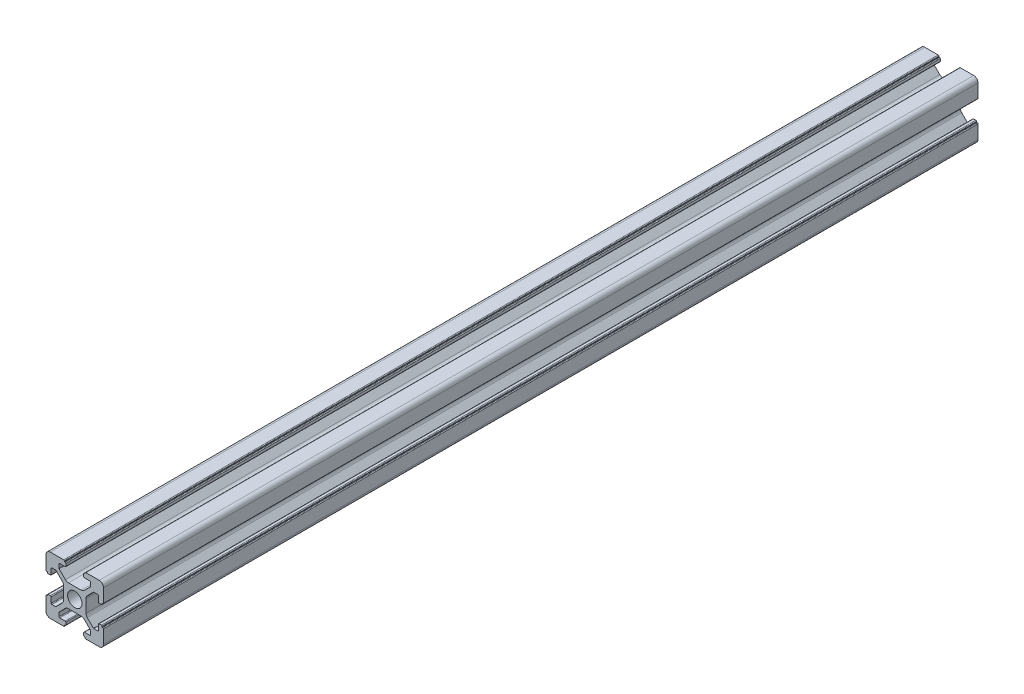
from build123d import *

# Parameters (mm, degrees)
SKETCH_1_R      = 2.5
EXTRUDE_1_DEPTH = 304


with BuildPart() as part:
    # 草图1 → 凸台-拉伸1 (new body)
    with BuildSketch(Plane.XY):
        with BuildLine():
            Line((-8.502261885, -10.002261885), (-3.85, -10.002261885))
            ThreePointArc((-3.85, -10.002261885), (-3.673223305, -9.929038581), (-3.6, -9.752261885))
            Line((-3.6, -9.752261885), (-3.6, -9.502261885))
            Line((-3.6, -9.502261885), (-3.35, -9.502261885))
            ThreePointArc((-3.35, -9.502261885), (-3.173223305, -9.429038581), (-3.1, -9.252261885))
            Line((-3.1, -9.252261885), (-3.1, -8.45))
            ThreePointArc((-3.1, -8.45), (-3.173223305, -8.273223305), (-3.35, -8.2))
            Line((-3.35, -8.2), (-5.25, -8.2))
            ThreePointArc((-5.25, -8.2), (-5.426776695, -8.126776695), (-5.5, -7.95))
            Line((-5.5, -7.95), (-5.5, -6.664213562))
            ThreePointArc((-5.5, -6.664213562), (-5.480969883, -6.568542704), (-5.426776695, -6.487436867))
            Line((-5.426776695, -6.487436867), (-3.278679656, -4.339339828))
            ThreePointArc((-3.278679656, -4.339339828), (-2.792044633, -4.014180701), (-2.218019485, -3.9))
            Line((-2.218019485, -3.9), (2.218019485, -3.9))
            ThreePointArc((2.218019485, -3.9), (2.792044633, -4.014180701), (3.278679656, -4.339339828))
            Line((3.278679656, -4.339339828), (5.426776695, -6.487436867))
            ThreePointArc((5.426776695, -6.487436867), (5.480969883, -6.568542704), (5.5, -6.664213562))
            Line((5.5, -6.664213562), (5.5, -7.95))
            ThreePointArc((5.5, -7.95), (5.426776695, -8.126776695), (5.25, -8.2))
            Line((5.25, -8.2), (3.35, -8.2))
            ThreePointArc((3.35, -8.2), (3.173223305, -8.273223305), (3.1, -8.45))
            Line((3.1, -8.45), (3.1, -9.252261885))
            ThreePointArc((3.1, -9.252261885), (3.173223305, -9.429038581), (3.35, -9.502261885))
            Line((3.35, -9.502261885), (3.6, -9.502261885))
            Line((3.6, -9.502261885), (3.6, -9.752261885))
            ThreePointArc((3.6, -9.752261885), (3.673223305, -9.929038581), (3.85, -10.002261885))
            Line((3.85, -10.002261885), (8.502261885, -10.002261885))
            ThreePointArc((8.502261885, -10.002261885), (9.562922057, -9.562922057), (10.002261885, -8.502261885))
            Line((10.002261885, -8.502261885), (10.002261885, -3.85))
            ThreePointArc((10.002261885, -3.85), (9.929038581, -3.673223305), (9.752261885, -3.6))
            Line((9.752261885, -3.6), (9.502261885, -3.6))
            Line((9.502261885, -3.6), (9.502261885, -3.35))
            ThreePointArc((9.502261885, -3.35), (9.429038581, -3.173223305), (9.252261885, -3.1))
            Line((9.252261885, -3.1), (8.45, -3.1))
            ThreePointArc((8.45, -3.1), (8.273223305, -3.173223305), (8.2, -3.35))
            Line((8.2, -3.35), (8.2, -5.25))
            ThreePointArc((8.2, -5.25), (8.126776695, -5.426776695), (7.95, -5.5))
            Line((7.95, -5.5), (6.664213562, -5.5))
            ThreePointArc((6.664213562, -5.5), (6.568542704, -5.480969883), (6.487436867, -5.426776695))
            Line((6.487436867, -5.426776695), (4.339339828, -3.278679656))
            ThreePointArc((4.339339828, -3.278679656), (4.014180701, -2.792044633), (3.9, -2.218019485))
            Line((3.9, -2.218019485), (3.9, 2.218019485))
            ThreePointArc((3.9, 2.218019485), (4.014180701, 2.792044633), (4.339339828, 3.278679656))
            Line((4.339339828, 3.278679656), (6.487436867, 5.426776695))
            ThreePointArc((6.487436867, 5.426776695), (6.568542704, 5.480969883), (6.664213562, 5.5))
            Line((6.664213562, 5.5), (7.95, 5.5))
            ThreePointArc((7.95, 5.5), (8.126776695, 5.426776695), (8.2, 5.25))
            Line((8.2, 5.25), (8.2, 3.35))
            ThreePointArc((8.2, 3.35), (8.273223305, 3.173223305), (8.45, 3.1))
            Line((8.45, 3.1), (9.252261885, 3.1))
            ThreePointArc((9.252261885, 3.1), (9.429038581, 3.173223305), (9.502261885, 3.35))
            Line((9.502261885, 3.35), (9.502261885, 3.6))
            Line((9.502261885, 3.6), (9.752261885, 3.6))
            ThreePointArc((9.752261885, 3.6), (9.929038581, 3.673223305), (10.002261885, 3.85))
            Line((10.002261885, 3.85), (10.002261885, 8.502261885))
            ThreePointArc((10.002261885, 8.502261885), (9.562922057, 9.562922057), (8.502261885, 10.002261885))
            Line((8.502261885, 10.002261885), (3.85, 10.002261885))
            ThreePointArc((3.85, 10.002261885), (3.673223305, 9.929038581), (3.6, 9.752261885))
            Line((3.6, 9.752261885), (3.6, 9.502261885))
            Line((3.6, 9.502261885), (3.35, 9.502261885))
            ThreePointArc((3.35, 9.502261885), (3.173223305, 9.429038581), (3.1, 9.252261885))
            Line((3.1, 9.252261885), (3.1, 8.45))
            ThreePointArc((3.1, 8.45), (3.173223305, 8.273223305), (3.35, 8.2))
            Line((3.35, 8.2), (5.25, 8.2))
            ThreePointArc((5.25, 8.2), (5.426776695, 8.126776695), (5.5, 7.95))
            Line((5.5, 7.95), (5.5, 6.664213562))
            ThreePointArc((5.5, 6.664213562), (5.480969883, 6.568542704), (5.426776695, 6.487436867))
            Line((5.426776695, 6.487436867), (3.278679656, 4.339339828))
            ThreePointArc((3.278679656, 4.339339828), (2.792044633, 4.014180701), (2.218019485, 3.9))
            Line((2.218019485, 3.9), (-2.218019485, 3.9))
            ThreePointArc((-2.218019485, 3.9), (-2.792044633, 4.014180701), (-3.278679656, 4.339339828))
            Line((-3.278679656, 4.339339828), (-5.426776695, 6.487436867))
            ThreePointArc((-5.426776695, 6.487436867), (-5.480969883, 6.568542704), (-5.5, 6.664213562))
            Line((-5.5, 6.664213562), (-5.5, 7.95))
            ThreePointArc((-5.5, 7.95), (-5.426776695, 8.126776695), (-5.25, 8.2))
            Line((-5.25, 8.2), (-3.35, 8.2))
            ThreePointArc((-3.35, 8.2), (-3.173223305, 8.273223305), (-3.1, 8.45))
            Line((-3.1, 8.45), (-3.1, 9.252261885))
            ThreePointArc((-3.1, 9.252261885), (-3.173223305, 9.429038581), (-3.35, 9.502261885))
            Line((-3.35, 9.502261885), (-3.6, 9.502261885))
            Line((-3.6, 9.502261885), (-3.6, 9.752261885))
            ThreePointArc((-3.6, 9.752261885), (-3.673223305, 9.929038581), (-3.85, 10.002261885))
            Line((-3.85, 10.002261885), (-8.502261885, 10.002261885))
            ThreePointArc((-8.502261885, 10.002261885), (-9.562922057, 9.562922057), (-10.002261885, 8.502261885))
            Line((-10.002261885, 8.502261885), (-10.002261885, 3.85))
            ThreePointArc((-10.002261885, 3.85), (-9.929038581, 3.673223305), (-9.752261885, 3.6))
            Line((-9.752261885, 3.6), (-9.502261885, 3.6))
            Line((-9.502261885, 3.6), (-9.502261885, 3.35))
            ThreePointArc((-9.502261885, 3.35), (-9.429038581, 3.173223305), (-9.252261885, 3.1))
            Line((-9.252261885, 3.1), (-8.45, 3.1))
            ThreePointArc((-8.45, 3.1), (-8.273223305, 3.173223305), (-8.2, 3.35))
            Line((-8.2, 3.35), (-8.2, 5.25))
            ThreePointArc((-8.2, 5.25), (-8.126776695, 5.426776695), (-7.95, 5.5))
            Line((-7.95, 5.5), (-6.664213562, 5.5))
            ThreePointArc((-6.664213562, 5.5), (-6.568542704, 5.480969883), (-6.487436867, 5.426776695))
            Line((-6.487436867, 5.426776695), (-4.339339828, 3.278679656))
            ThreePointArc((-4.339339828, 3.278679656), (-4.014180701, 2.792044633), (-3.9, 2.218019485))
            Line((-3.9, 2.218019485), (-3.9, -2.218019485))
            ThreePointArc((-3.9, -2.218019485), (-4.014180701, -2.792044633), (-4.339339828, -3.278679656))
            Line((-4.339339828, -3.278679656), (-6.487436867, -5.426776695))
            ThreePointArc((-6.487436867, -5.426776695), (-6.568542704, -5.480969883), (-6.664213562, -5.5))
            Line((-6.664213562, -5.5), (-7.95, -5.5))
            ThreePointArc((-7.95, -5.5), (-8.126776695, -5.426776695), (-8.2, -5.25))
            Line((-8.2, -5.25), (-8.2, -3.35))
            ThreePointArc((-8.2, -3.35), (-8.273223305, -3.173223305), (-8.45, -3.1))
            Line((-8.45, -3.1), (-9.252261885, -3.1))
            ThreePointArc((-9.252261885, -3.1), (-9.429038581, -3.173223305), (-9.502261885, -3.35))
            Line((-9.502261885, -3.35), (-9.502261885, -3.6))
            Line((-9.502261885, -3.6), (-9.752261885, -3.6))
            ThreePointArc((-9.752261885, -3.6), (-9.929038581, -3.673223305), (-10.002261885, -3.85))
            Line((-10.002261885, -3.85), (-10.002261885, -8.502261885))
            ThreePointArc((-10.002261885, -8.502261885), (-9.562922057, -9.562922057), (-8.502261885, -10.002261885))
        make_face()
        Circle(SKETCH_1_R, mode=Mode.SUBTRACT)
    extrude(amount=EXTRUDE_1_DEPTH)


solid = part.part
